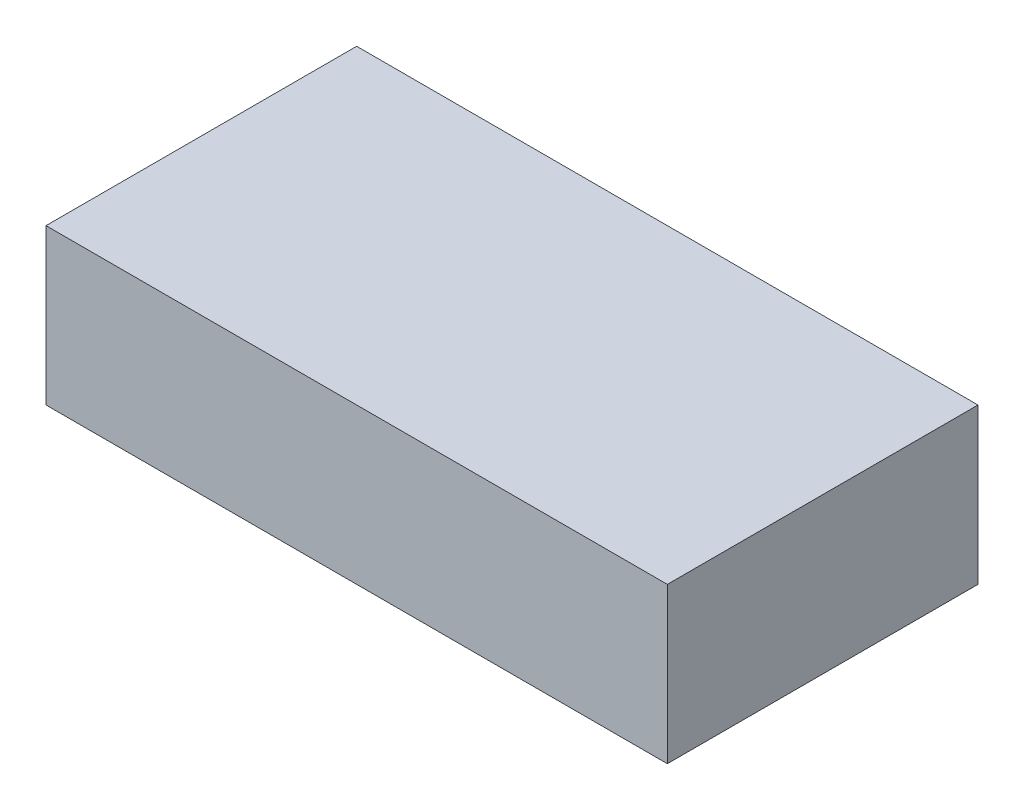
from build123d import *

# Parameters (mm, degrees)
SKETCH1_W           = 50.8
SKETCH1_H           = 25.4
BOSS_EXTRUDE1_DEPTH = 6.35


with BuildPart() as part:
    # Sketch1 → Boss-Extrude1 (new body, symmetric)
    with BuildSketch(Plane(origin=(0, 0, 0), x_dir=(1, 0, 0), z_dir=(0, 1, 0))):
        with Locations((25.4, 12.7)):
            Rectangle(SKETCH1_W, SKETCH1_H)
    extrude(amount=BOSS_EXTRUDE1_DEPTH, both=True)


solid = part.part
